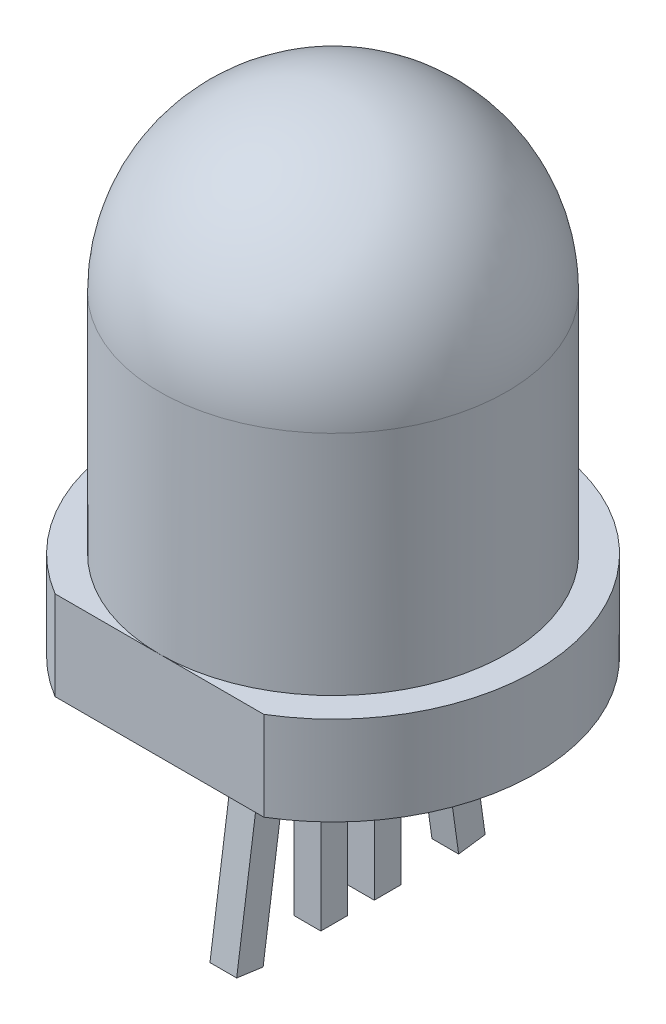
from build123d import *

# Parameters (mm, degrees)
ESQUISSE1_R        = 3.9
BOSS_EXTRU_1_DEPTH = 9
CONG_1_R           = 3.9
BOSS_EXTRU_2_DEPTH = 2
ESQUISSE3_W        = 0.6
ESQUISSE3_H        = 0.6
BOSS_EXTRU_3_DEPTH = 4.9
ESQUISSE6_W        = 0.6
ESQUISSE6_H        = 0.6
BOSS_EXTRU_4_DEPTH = 5
ESQUISSE8_W        = 0.6
ESQUISSE8_H        = 0.6
BOSS_EXTRU_5_DEPTH = 5


with BuildPart() as part:
    # Esquisse1 → Boss.-Extru.1 (new body)
    with BuildSketch(Plane(origin=(0, 0, 0), x_dir=(1, 0, 0), z_dir=(0, 1, 0))):
        Circle(ESQUISSE1_R)
    extrude(amount=BOSS_EXTRU_1_DEPTH)

    # Congé1
    cong_1_edges = [part.edges().sort_by_distance(p)[0] for p in [
        (-3.9, 9, 0),
    ]]
    fillet(cong_1_edges, radius=CONG_1_R)

    # Esquisse2 → Boss.-Extru.2 (add)
    with BuildSketch(Plane.XZ):
        with BuildLine():
            Line((2.343608329, 3.9), (-2.343608329, 3.9))
            ThreePointArc((-2.343608329, 3.9), (0, -4.55), (2.343608329, 3.9))
        make_face()
    extrude(amount=BOSS_EXTRU_2_DEPTH)

    # Esquisse3 → Boss.-Extru.3 (add)
    with BuildSketch(Plane.XZ.offset(2)):
        with Locations((0, 0.275)):
            Rectangle(ESQUISSE3_W, ESQUISSE3_H)
        with Locations((0, -0.925)):
            Rectangle(ESQUISSE3_W, ESQUISSE3_H)
    extrude(amount=BOSS_EXTRU_3_DEPTH)

    # Esquisse6 → Boss.-Extru.4 (add)
    with BuildSketch(Plane(origin=(0, -2.123198642, 0.298396109), x_dir=(-1, 0, 0), z_dir=(0, -0.990268069, 0.139173101))):
        with Locations((0, -1.185218779)):
            Rectangle(ESQUISSE6_W, ESQUISSE6_H)
    extrude(amount=BOSS_EXTRU_4_DEPTH)

    # Esquisse8 → Boss.-Extru.5 (add)
    with BuildSketch(Plane(origin=(0, -2.212780783, -0.310986058), x_dir=(-1, 0, 0), z_dir=(0, -0.990268069, -0.139173101))):
        with Locations((0, 1.828893024)):
            Rectangle(ESQUISSE8_W, ESQUISSE8_H)
    extrude(amount=BOSS_EXTRU_5_DEPTH)


solid = part.part
